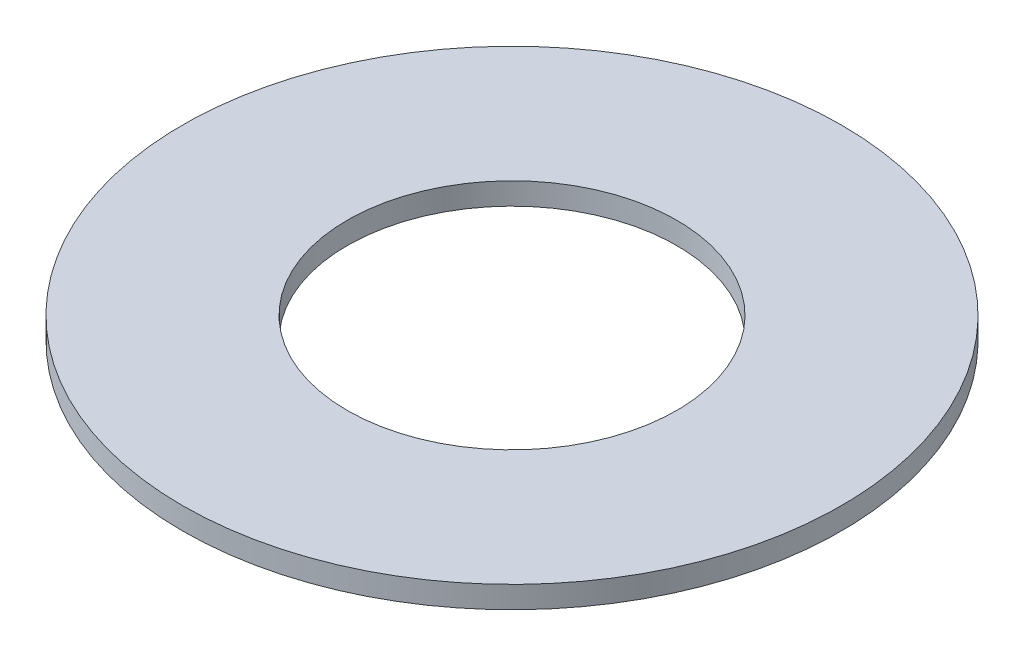
from build123d import *

# Parameters (mm, degrees)
SKETCH1_R           = 6
SKETCH1_R_2         = 3
BOSS_EXTRUDE1_DEPTH = 0.4


with BuildPart() as part:
    # Sketch1 → Boss-Extrude1 (new body)
    with BuildSketch(Plane(origin=(0, 0, 0), x_dir=(1, 0, 0), z_dir=(0, 1, 0))):
        Circle(SKETCH1_R)
        Circle(SKETCH1_R_2, mode=Mode.SUBTRACT)
    extrude(amount=BOSS_EXTRUDE1_DEPTH)


solid = part.part
